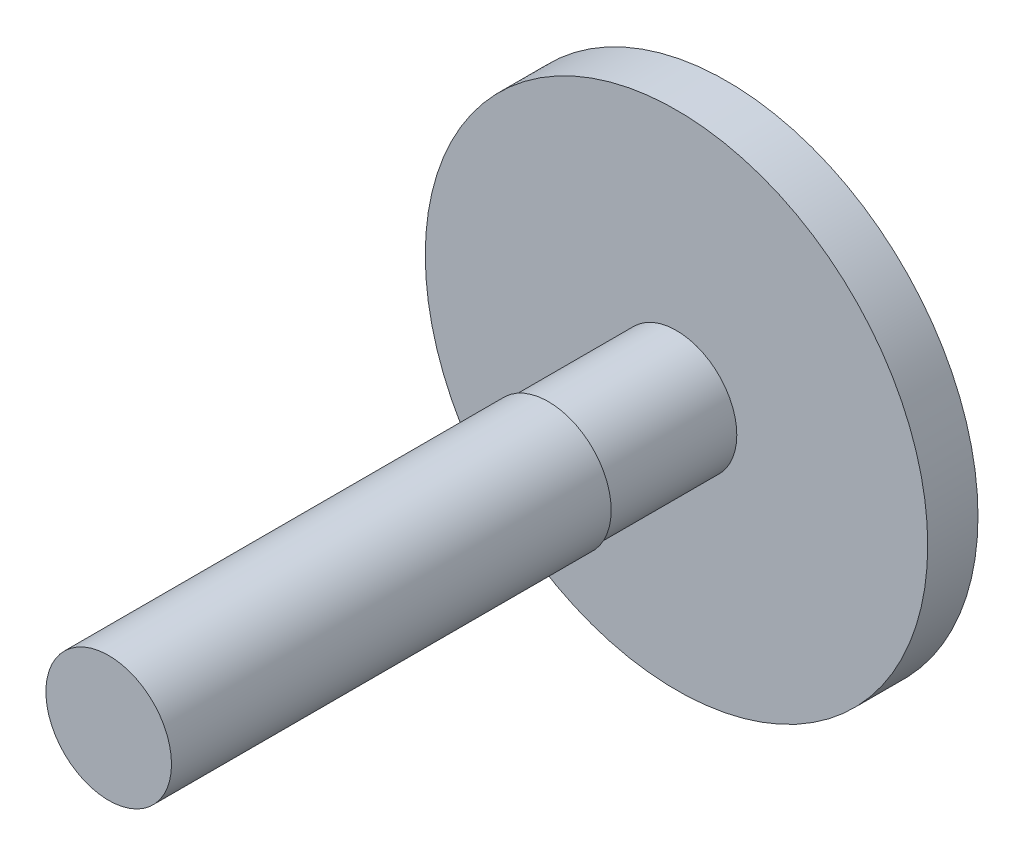
from build123d import *

# Parameters (mm, degrees)
SKETCH1_R      = 10
EXTRUDE1_DEPTH = 2
SKETCH2_R      = 2.4
EXTRUDE2_DEPTH = 5.1
SKETCH3_R      = 2.5
EXTRUDE3_DEPTH = 17.5


with BuildPart() as part:
    # Sketch1 → Extrude1 (new body)
    with BuildSketch(Plane.XY):
        Circle(SKETCH1_R)
    extrude(amount=EXTRUDE1_DEPTH)

    # Sketch2 → Extrude2 (add)
    with BuildSketch(Plane.XY.offset(2)):
        Circle(SKETCH2_R)
    extrude(amount=EXTRUDE2_DEPTH)

    # Sketch3 → Extrude3 (add)
    with BuildSketch(Plane.XY.offset(7.1)):
        Circle(SKETCH3_R)
    extrude(amount=EXTRUDE3_DEPTH)


solid = part.part
